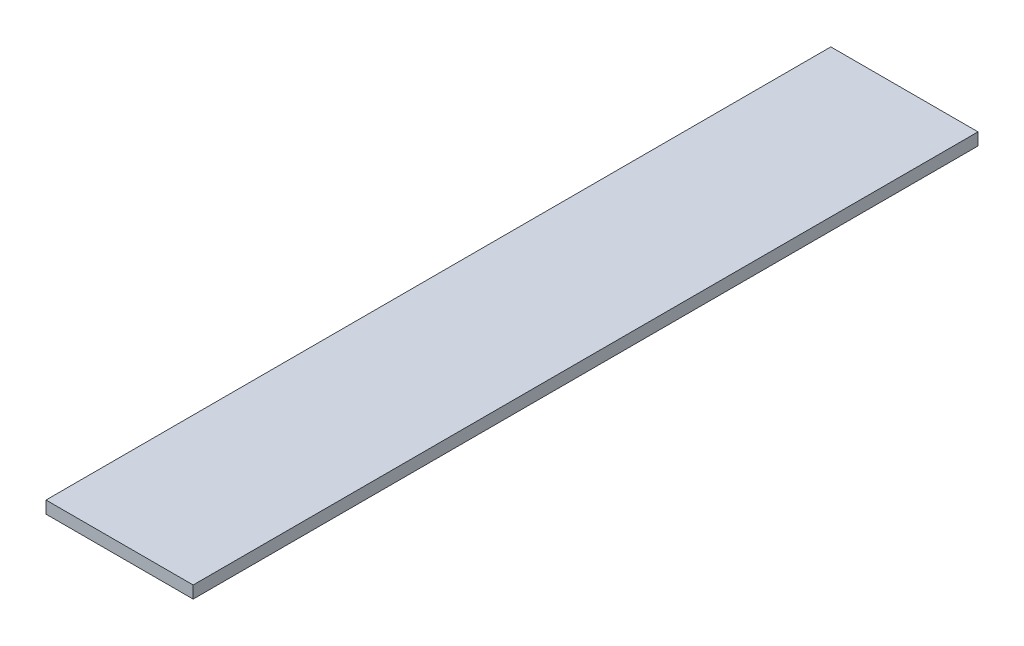
from build123d import *

# Parameters (mm, degrees)
SKETCH1_W           = 19.05
SKETCH1_H           = 1.5875
BOSS_EXTRUDE1_DEPTH = 101.6


with BuildPart() as part:
    # Sketch1 → Boss-Extrude1 (new body)
    with BuildSketch(Plane.XY):
        Rectangle(SKETCH1_W, SKETCH1_H)
    extrude(amount=BOSS_EXTRUDE1_DEPTH)


solid = part.part
